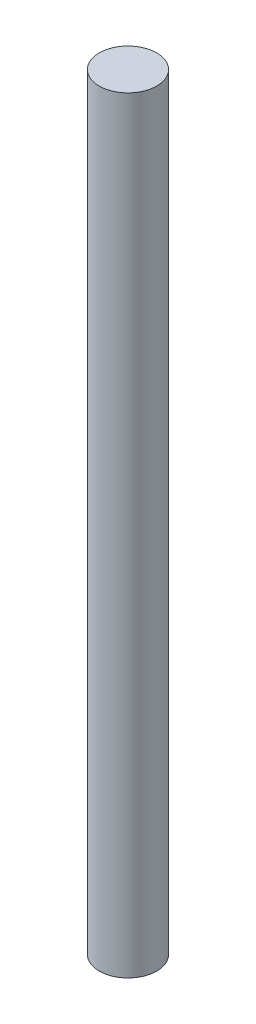
from build123d import *

# Parameters (mm, degrees)
IZIM1_R                     = 3
Y_KSEKLIK_EKSTR_ZYON1_DEPTH = 80


with BuildPart() as part:
    # Çizim1 → Yükseklik-Ekstrüzyon1 (new body)
    with BuildSketch(Plane(origin=(0, 0, 0), x_dir=(1, 0, 0), z_dir=(0, 1, 0))):
        Circle(IZIM1_R)
    extrude(amount=Y_KSEKLIK_EKSTR_ZYON1_DEPTH)


solid = part.part
